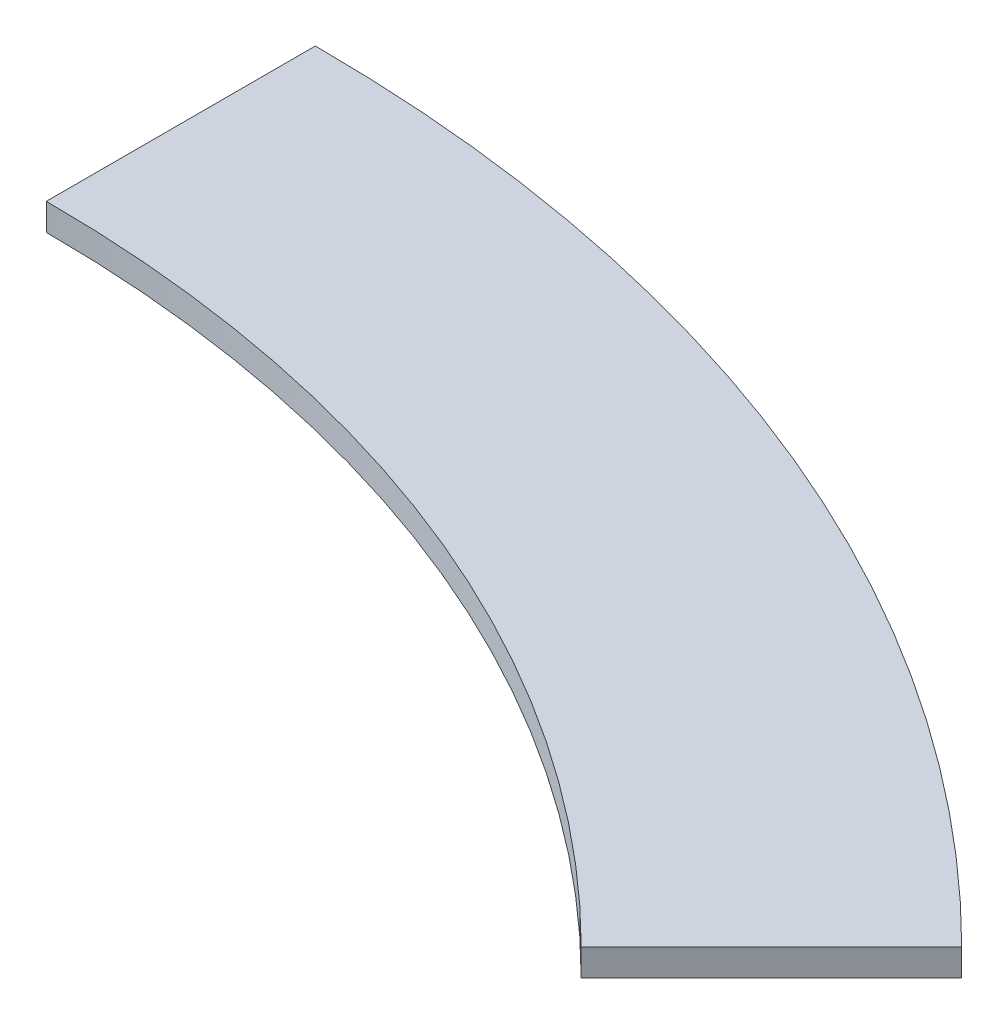
from build123d import *

# Parameters (mm, degrees)
BOSS_EXTRUDE1_DEPTH = 10


with BuildPart() as part:
    # Sketch1 → Boss-Extrude1 (new body)
    with BuildSketch(Plane(origin=(0, 0, 0), x_dir=(1, 0, 0), z_dir=(0, 1, 0))):
        with BuildLine():
            ThreePointArc((0, 580), (221.956390772, 535.850128857), (410.121933088, 410.121933088))
            Line((410.121933088, 410.121933088), (339.41125497, 339.41125497))
            ThreePointArc((339.41125497, 339.41125497), (183.688047535, 443.462175605), (0, 480))
            Line((0, 480), (0, 580))
        make_face()
    extrude(amount=BOSS_EXTRUDE1_DEPTH)


solid = part.part
